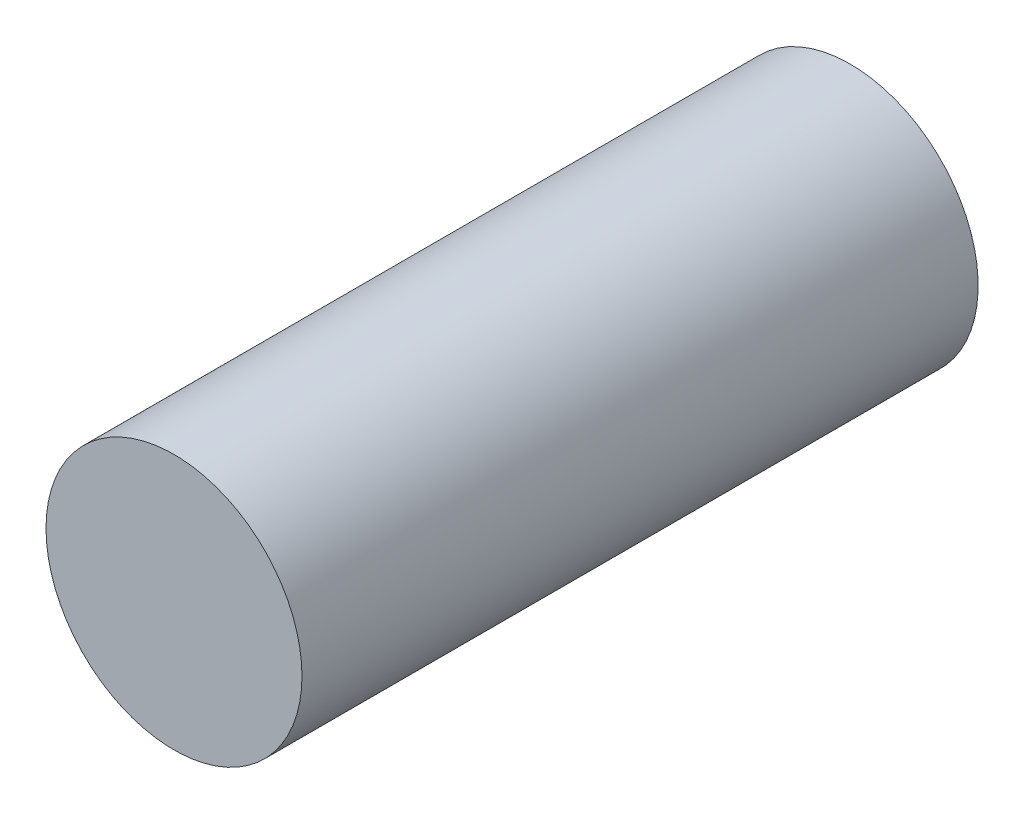
from build123d import *

# Parameters (mm, degrees)
SKETCH1_R           = 50.8
BOSS_EXTRUDE1_DEPTH = 304.8
CUT_REVOLVE3_ANGLE  = 180


with BuildPart() as part:
    # Sketch1 → Boss-Extrude1 (new body)
    with BuildSketch(Plane.XY):
        Circle(SKETCH1_R)
    extrude(amount=BOSS_EXTRUDE1_DEPTH)

    # Sketch2 → Cut-Revolve3 (revolve, cut)
    with BuildSketch(Plane(origin=(0, 0, 0), x_dir=(-1, 0, 0), z_dir=(0, 0, -1))):
        with BuildLine():
            Line((0, 62.5), (0, -62.5))
            ThreePointArc((0, -62.5), (62.5, 0), (0, 62.5))
        make_face()
    revolve(axis=Axis((0, -62.5, 0), (0, 1, 0)), revolution_arc=CUT_REVOLVE3_ANGLE, mode=Mode.SUBTRACT)


solid = part.part
